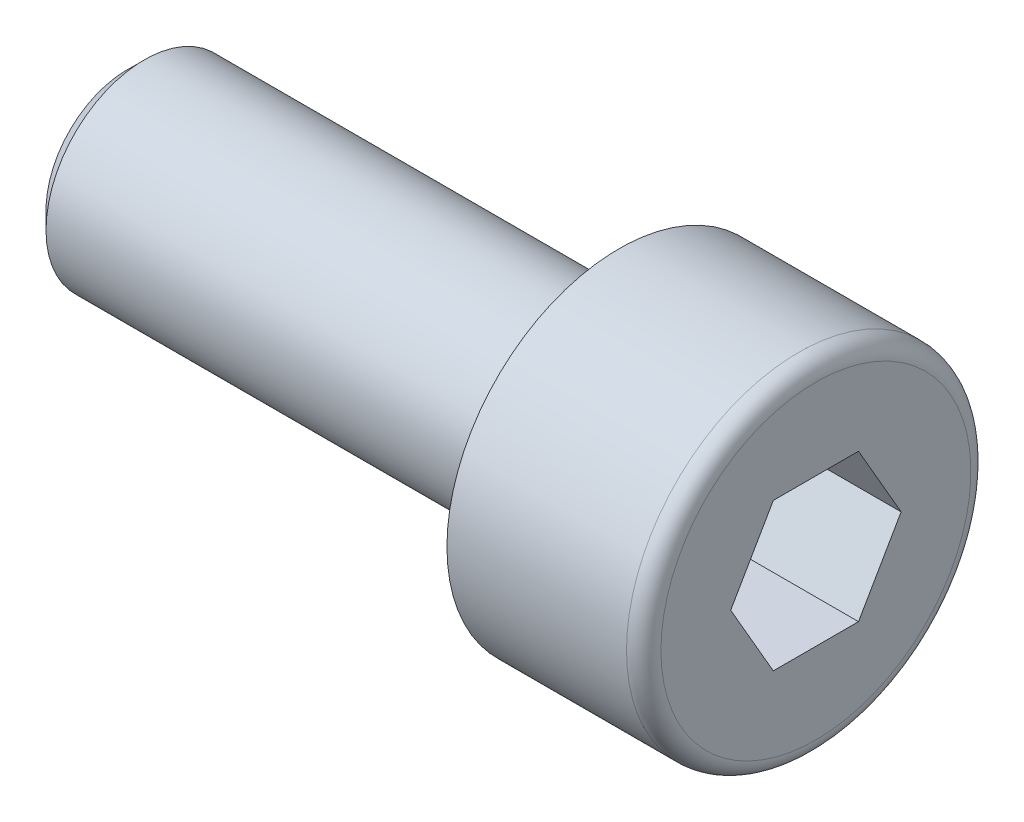
from build123d import *

# Parameters (mm, degrees)
SFAZOWANIE1_SIZE           = 0.35
ZAOKR_GLENIE1_R            = 0.35
WYTNIJ_WYCI_GNI_CIE1_DEPTH = 3


with BuildPart() as part:
    # Szkic1 → Obrót1 (revolve)
    with BuildSketch(Plane.XY):
        Polygon((0, 0), (0, 3.5), (-4, 3.5), (-4, 2), (-14, 2), (-14, 0), align=None)
    revolve(axis=Axis((-123.158940217, 0, 0), (1, 0, 0)))

    # Sfazowanie1
    sfazowanie1_edges = [part.edges().sort_by_distance(p)[0] for p in [
        (-14, -2, 0),
    ]]
    chamfer(sfazowanie1_edges, length=SFAZOWANIE1_SIZE)

    # Zaokrąglenie1
    zaokr_glenie1_edges = [part.edges().sort_by_distance(p)[0] for p in [
        (0, -3.5, 0),
    ]]
    fillet(zaokr_glenie1_edges, radius=ZAOKR_GLENIE1_R)

    # Szkic2 → Wytnij-wyciągnięcie1 (cut)
    with BuildSketch(Plane(origin=(0, 0, 0), x_dir=(0, 0, -1), z_dir=(1, 0, 0))):
        Polygon((1.732050808, 0), (0.866025404, 1.5), (-0.866025404, 1.5), (-1.732050808, 0), (-0.866025404, -1.5), (0.866025404, -1.5), align=None)
    extrude(amount=-WYTNIJ_WYCI_GNI_CIE1_DEPTH, mode=Mode.SUBTRACT)


solid = part.part
